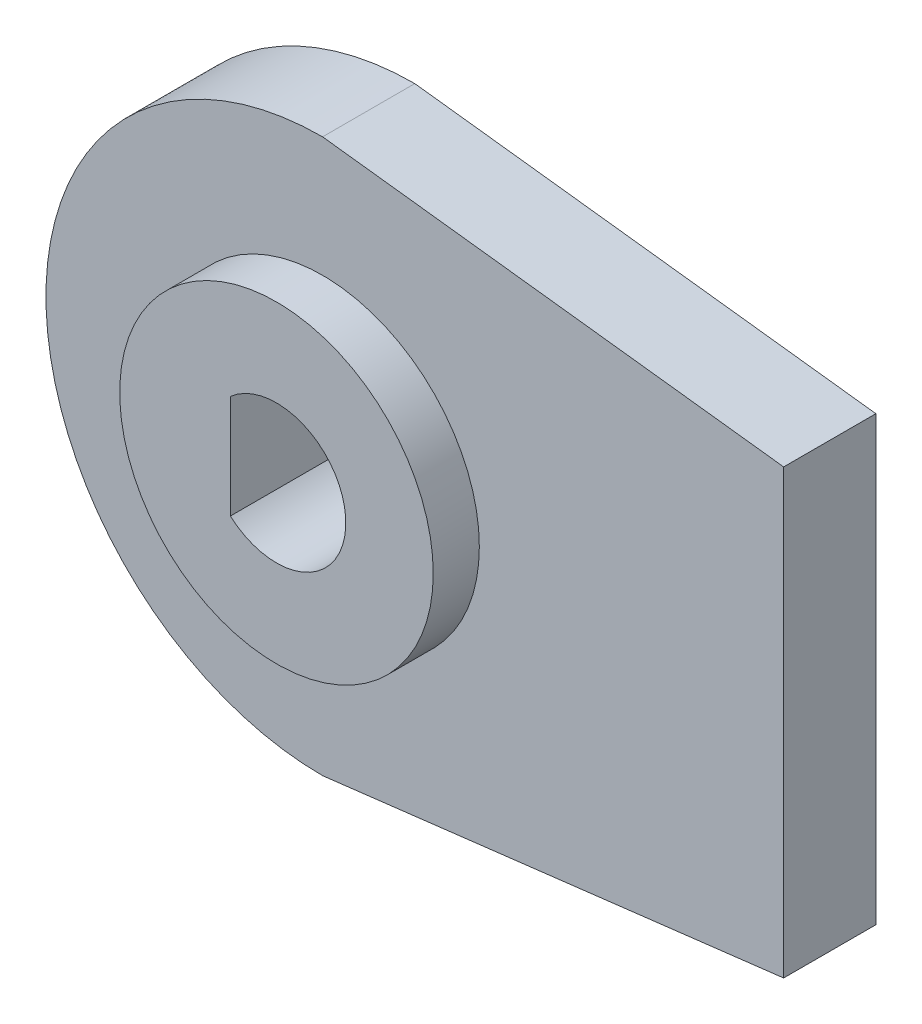
from build123d import *

# Parameters (mm, degrees)
BOSS_EXTRUDE1_DEPTH = 2
SKETCH7_R           = 3.4
BOSS_EXTRUDE2_DEPTH = 1
CUT_EXTRUDE3_DEPTH  = 4


with BuildPart() as part:
    # Sketch2 → Boss-Extrude1 (new body)
    with BuildSketch(Plane.XY):
        with BuildLine():
            Line((10, -4.8), (10, 4.8))
            Line((10, 4.8), (0, 6))
            ThreePointArc((0, 6), (-6, 0), (0, -6))
            Line((0, -6), (10, -4.8))
        make_face()
    extrude(amount=BOSS_EXTRUDE1_DEPTH)

    # Sketch7 → Boss-Extrude2 (add)
    with BuildSketch(Plane.XY.offset(2)):
        Circle(SKETCH7_R)
    extrude(amount=BOSS_EXTRUDE2_DEPTH)

    # Sketch8 → Cut-Extrude3 (cut, through all)
    with BuildSketch(Plane.XY.offset(3)):
        with BuildLine():
            Line((-1, 1.122930178), (-1, -1.122930178))
            ThreePointArc((-1, -1.122930178), (1.503652947, 0), (-1, 1.122930178))
        make_face()
    extrude(amount=-CUT_EXTRUDE3_DEPTH, mode=Mode.SUBTRACT)


solid = part.part
